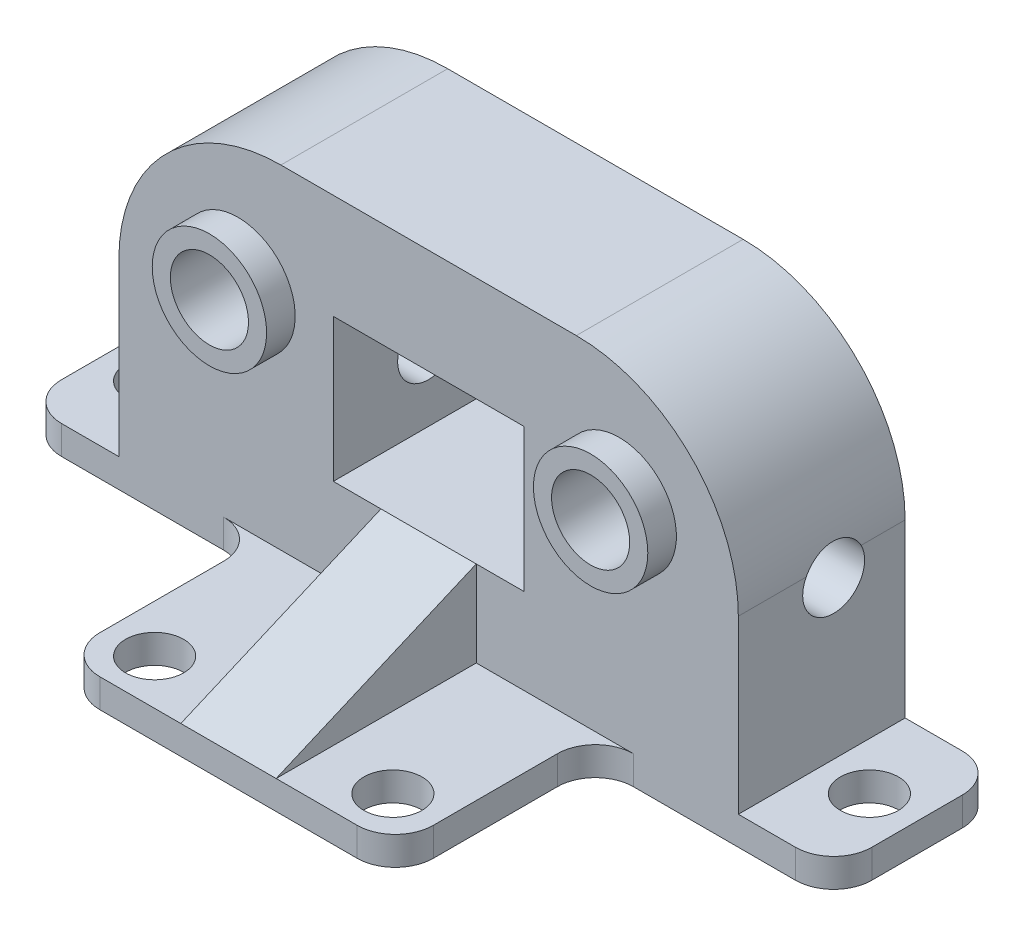
from build123d import *

# Parameters (mm, degrees)
SKICA1_W                 = 85
SKICA1_H                 = 17.5
SKICA1_R                 = 3.05
P_IDAT_VYSUNUT_M1_DEPTH  = 3
SKICA3_W                 = 65
SKICA3_H                 = 35
P_IDAT_VYSUNUT_M2_DEPTH  = 17.5
ZAOBLIT2_R               = 17
SKICA4_R                 = 6
SKICA4_R_2               = 4.1
P_IDAT_VYSUNUT_M3_DEPTH  = 3
ODEBRAT_START            = -4
SKICA4_2_R               = 4.1
ODEBRAT_VYSUNUT_M1_DEPTH = 4
SKICA5_W                 = 20
SKICA5_H                 = 15
ODEBRAT_VYSUNUT_M2_DEPTH = 60.636398282
SKICA7_R                 = 3.25
ODEBRAT_VYSUNUT_M4_DEPTH = 50
SKICA8_W                 = 35
SKICA8_H                 = 21
SKICA8_R                 = 3.05
P_IDAT_VYSUNUT_M4_DEPTH  = 3
ZAOBLIT1_R               = 4
EBRO4_REACH              = 66.306
SKICA12_WALL_W           = 153.460110402
SKICA12_WALL_H           = 10


with BuildPart() as part:
    # Skica1 → P_idat vysunut_m1 (new body)
    with BuildSketch(Plane(origin=(0, 0, 0), x_dir=(1, 0, 0), z_dir=(0, 1, 0))):
        Rectangle(SKICA1_W, SKICA1_H)
        with Locations((-37.5, 0)):
            Circle(SKICA1_R, mode=Mode.SUBTRACT)
        with Locations((37.5, 0)):
            Circle(SKICA1_R, mode=Mode.SUBTRACT)
    extrude(amount=P_IDAT_VYSUNUT_M1_DEPTH)

    # Skica3 → P_idat vysunut_m2 (add)
    with BuildSketch(Plane.XY.offset(8.75)):
        with Locations((0, 20.5)):
            Rectangle(SKICA3_W, SKICA3_H)
    extrude(amount=-P_IDAT_VYSUNUT_M2_DEPTH)

    # Zaoblit2
    zaoblit2_edges = [part.edges().sort_by_distance(p)[0] for p in [
        (-32.5, 38, 0),
        (32.5, 38, 0),
    ]]
    fillet(zaoblit2_edges, radius=ZAOBLIT2_R)

    # Skica4 → P_idat vysunut_m3 (add)
    # profile 1 of 2: a face of its own
    with BuildSketch(Plane.XY.offset(8.75)):
        with Locations((-20, 25)):
            Circle(SKICA4_R)
        with Locations((-20, 25)):
            Circle(SKICA4_R_2, mode=Mode.SUBTRACT)
    # profile 2 of 2: a face of its own
    with BuildSketch(Plane.XY.offset(8.75)):
        with Locations((20, 25)):
            Circle(SKICA4_R)
        with Locations((20, 25)):
            Circle(SKICA4_R_2, mode=Mode.SUBTRACT)
    extrude(amount=P_IDAT_VYSUNUT_M3_DEPTH)

    # Skica4_2 → Odebrat vysunut_m1 (cut)
    with BuildSketch(Plane.XY.offset(8.75).offset(ODEBRAT_START)):
        with Locations((-20, 25)):
            Circle(SKICA4_2_R)
        with Locations((20, 25)):
            Circle(SKICA4_2_R)
    extrude(amount=ODEBRAT_VYSUNUT_M1_DEPTH, mode=Mode.SUBTRACT)

    # Skica5 → Odebrat vysunut_m2 (cut, through all)
    with BuildSketch(Plane.XY.offset(8.75)):
        with Locations((0, 19.5)):
            Rectangle(SKICA5_W, SKICA5_H)
    extrude(amount=-ODEBRAT_VYSUNUT_M2_DEPTH, mode=Mode.SUBTRACT)

    # Skica7 → Odebrat vysunut_m4 (cut)
    with BuildSketch(Plane(origin=(32.5, 0, 0), x_dir=(0, 0, -1), z_dir=(1, 0, 0))):
        with Locations((1.25, 19.5)):
            Circle(SKICA7_R)
    extrude(amount=-ODEBRAT_VYSUNUT_M4_DEPTH, mode=Mode.SUBTRACT)

    # Skica8 → P_idat vysunut_m4 (add)
    with BuildSketch(Plane.XZ):
        with Locations((0, 19.25)):
            Rectangle(SKICA8_W, SKICA8_H)
        with Locations((-12.5, 25)):
            Circle(SKICA8_R, mode=Mode.SUBTRACT)
        with Locations((12.5, 25)):
            Circle(SKICA8_R, mode=Mode.SUBTRACT)
    extrude(amount=-P_IDAT_VYSUNUT_M4_DEPTH)

    # Zaoblit1
    zaoblit1_edges = [part.edges().sort_by_distance(p)[0] for p in [
        (42.5, 1.5, 8.75),
        (42.5, 1.5, -8.75),
        (-42.5, 1.5, -8.75),
        (-42.5, 1.5, 8.75),
        (17.5, 1.5, 8.75),
        (-17.5, 1.5, 8.75),
        (-17.5, 1.5, 29.75),
        (17.5, 1.5, 29.75),
    ]]
    fillet(zaoblit1_edges, radius=ZAOBLIT1_R)

    # Skica12 wall → ebro4 (add, up to next)
    with BuildSketch(Plane(origin=(0, 7.5, 19.25), x_dir=(0, 0.393919298579, -0.919145030018), z_dir=(0, 0.919145030018, 0.393919298579)), mode=Mode.PRIVATE) as ebro4_sk1:
        Rectangle(SKICA12_WALL_W, SKICA12_WALL_H)
    ebro4_tool1 = extrude(ebro4_sk1.sketch, amount=-EBRO4_REACH, mode=Mode.PRIVATE) - part.part
    add(ebro4_tool1.solids().sort_by_distance((0, 7.5, 19.25))[0])


solid = part.part
